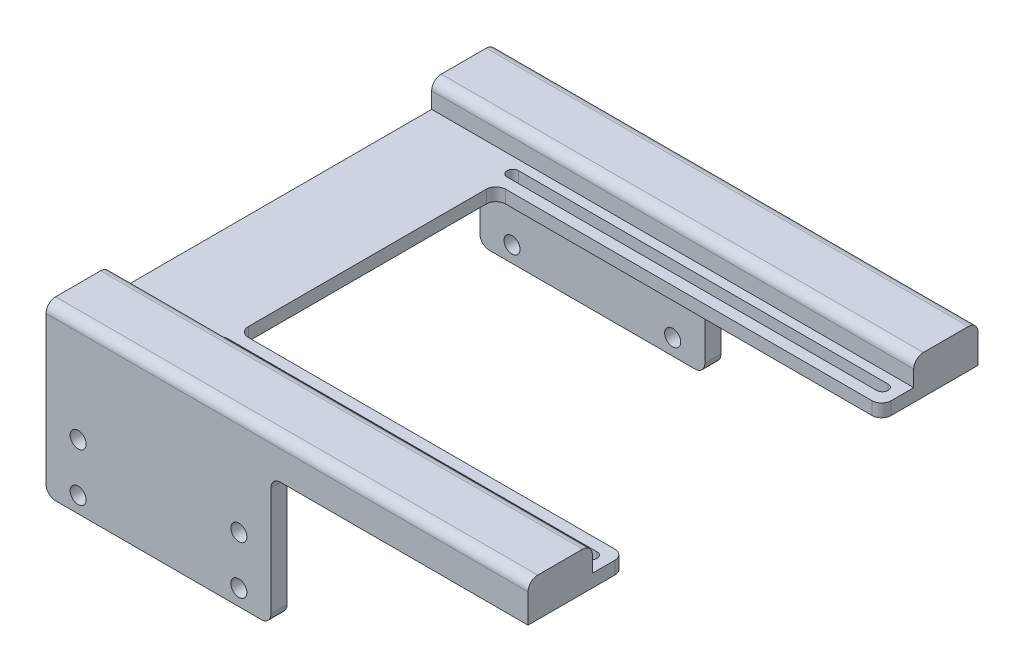
from build123d import *

# Parameters (mm, degrees)
SKETCH1_W               = 150
SKETCH1_H               = 140
BOSS_EXTRUDE1_DEPTH     = 12
SKETCH4_W               = 70
SKETCH4_H               = 140
BOSS_EXTRUDE2_DEPTH     = 40
SKETCH5_R               = 2.5
CUT_EXTRUDE1_DEPTH      = 141
SKETCH7_W               = 150
SKETCH7_H               = 100
CUT_EXTRUDE2_DEPTH      = 8
SKETCH8_W               = 120
SKETCH8_H               = 80
CUT_EXTRUDE3_DEPTH      = 41
CUT_EXTRUDE3_DEPTH_BACK = 13
CUT_EXTRUDE4_DEPTH      = 45
SKETCH11_W              = 130
SKETCH11_H              = 40
CUT_EXTRUDE6_DEPTH      = 71
FILLET5_R               = 3
FILLET6_R               = 3
FILLET7_R               = 3
FILLET8_R               = 3
FILLET9_R               = 3
FILLET10_R              = 3
FILLET11_R              = 3


with BuildPart() as part:
    # Sketch1 → Boss-Extrude1 (new body)
    with BuildSketch(Plane(origin=(0, 0, 0), x_dir=(1, 0, 0), z_dir=(0, 1, 0))):
        Rectangle(SKETCH1_W, SKETCH1_H)
    extrude(amount=BOSS_EXTRUDE1_DEPTH)

    # Sketch4 → Boss-Extrude2 (add)
    with BuildSketch(Plane.XZ):
        with Locations((-40, 0)):
            Rectangle(SKETCH4_W, SKETCH4_H)
    extrude(amount=BOSS_EXTRUDE2_DEPTH)

    # Sketch5 → Cut-Extrude1 (cut, through all)
    with BuildSketch(Plane.XY.offset(70)):
        with Locations((-65, -35)):
            Circle(SKETCH5_R)
        with Locations((-15, -35)):
            Circle(SKETCH5_R)
        with Locations((-15, -20)):
            Circle(SKETCH5_R)
        with Locations((-65, -20)):
            Circle(SKETCH5_R)
    extrude(amount=-CUT_EXTRUDE1_DEPTH, mode=Mode.SUBTRACT)

    # Sketch7 → Cut-Extrude2 (cut)
    with BuildSketch(Plane(origin=(0, 12, 0), x_dir=(1, 0, 0), z_dir=(0, 1, 0))):
        Rectangle(SKETCH7_W, SKETCH7_H)
    extrude(amount=-CUT_EXTRUDE2_DEPTH, mode=Mode.SUBTRACT)

    # Sketch8 → Cut-Extrude3 (cut, two sides)
    with BuildSketch(Plane.XZ) as cut_extrude3_sk:
        with Locations((15, 0)):
            Rectangle(SKETCH8_W, SKETCH8_H)
    extrude(amount=CUT_EXTRUDE3_DEPTH, mode=Mode.SUBTRACT)
    extrude(cut_extrude3_sk.sketch, amount=-CUT_EXTRUDE3_DEPTH_BACK, mode=Mode.SUBTRACT)

    # Sketch9 → Cut-Extrude4 (cut, through all)
    with BuildSketch(Plane(origin=(0, 4, 0), x_dir=(1, 0, 0), z_dir=(0, 1, 0))):
        with BuildLine():
            Line((-45, 47), (70, 47))
            ThreePointArc((70, 47), (71.75, 45.25), (70, 43.5))
            Line((70, 43.5), (-45, 43.5))
            ThreePointArc((-45, 43.5), (-46.75, 45.25), (-45, 47))
        make_face()
        with BuildLine():
            Line((-45, -47), (70, -47))
            ThreePointArc((70, -47), (71.75, -45.25), (70, -43.5))
            Line((70, -43.5), (-45, -43.5))
            ThreePointArc((-45, -43.5), (-46.75, -45.25), (-45, -47))
        make_face()
    extrude(amount=-CUT_EXTRUDE4_DEPTH, mode=Mode.SUBTRACT)

    # Sketch11 → Cut-Extrude6 (cut, through all)
    with BuildSketch(Plane(origin=(-5, 0, 0), x_dir=(0, 0, -1), z_dir=(1, 0, 0))):
        with Locations((0, -20)):
            Rectangle(SKETCH11_W, SKETCH11_H)
    extrude(amount=-CUT_EXTRUDE6_DEPTH, mode=Mode.SUBTRACT)

    # Fillet5
    fillet5_edges = [part.edges().sort_by_distance(p)[0] for p in [
        (-40, 0, -65),
        (-40, 0, 65),
    ]]
    fillet(fillet5_edges, radius=FILLET5_R)

    # Fillet6
    fillet6_edges = [part.edges().sort_by_distance(p)[0] for p in [
        (-5, 0, -67.5),
        (-5, 0, 67.5),
    ]]
    fillet(fillet6_edges, radius=FILLET6_R)

    # Fillet7
    fillet7_edges = [part.edges().sort_by_distance(p)[0] for p in [
        (0, 12, 70),
        (0, 12, -70),
    ]]
    fillet(fillet7_edges, radius=FILLET7_R)

    # Fillet8
    fillet8_edges = [part.edges().sort_by_distance(p)[0] for p in [
        (0, 12, -50),
        (0, 12, 50),
    ]]
    fillet(fillet8_edges, radius=FILLET8_R)

    # Fillet9
    fillet9_edges = [part.edges().sort_by_distance(p)[0] for p in [
        (-5, -40, 67.5),
        (-75, -40, -67.5),
        (-75, -40, 67.5),
        (-5, -40, -67.5),
    ]]
    fillet(fillet9_edges, radius=FILLET9_R)

    # Fillet10
    fillet10_edges = [part.edges().sort_by_distance(p)[0] for p in [
        (-45, 2, 40),
        (-45, 2, -40),
    ]]
    fillet(fillet10_edges, radius=FILLET10_R)

    # Fillet11
    fillet11_edges = [part.edges().sort_by_distance(p)[0] for p in [
        (75, 2, 40),
        (75, 2, -40),
    ]]
    fillet(fillet11_edges, radius=FILLET11_R)


solid = part.part
